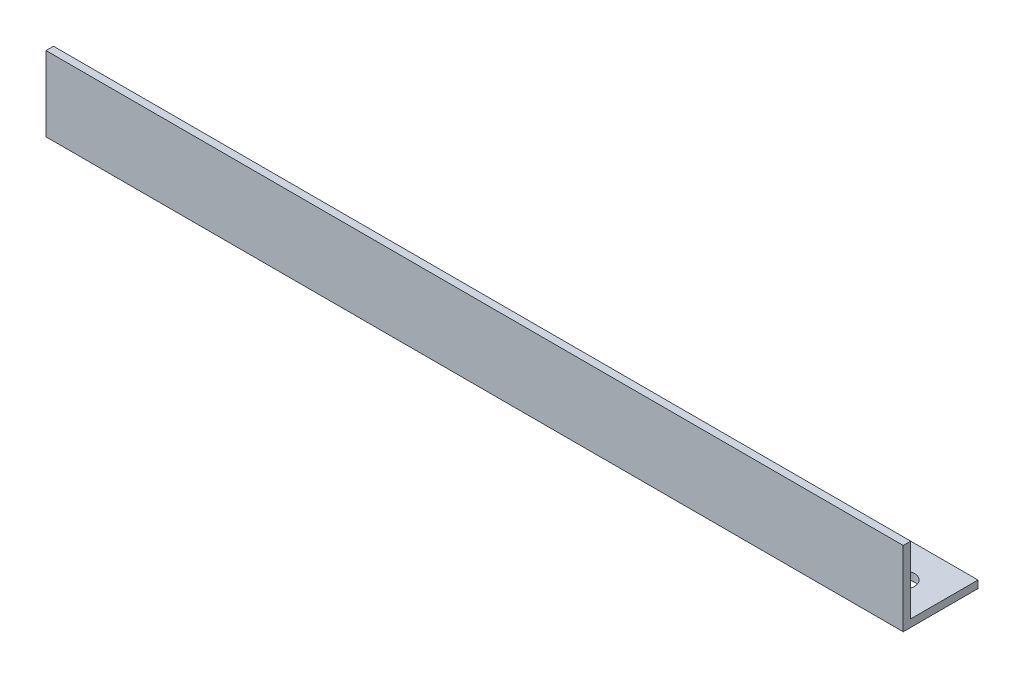
from build123d import *

# Parameters (mm, degrees)
EXTRUDE_1_DEPTH     = 172
SKETCH_2_R          = 2.25
CUT_EXTRUDE_1_DEPTH = 16


with BuildPart() as part:
    # Эскиз1 → Бобышка-Вытянуть1 (new body)
    with BuildSketch(Plane(origin=(0, 0, 0), x_dir=(0, 0, -1), z_dir=(1, 0, 0))):
        Polygon((0, 0), (0, 15), (1.5, 15), (1.5, 1.5), (15, 1.5), (15, 0), align=None)
    extrude(amount=EXTRUDE_1_DEPTH)

    # Эскиз2 → Вырез-Вытянуть1 (cut, through all)
    with BuildSketch(Plane.XZ):
        with Locations((7.5, -7.5)):
            Circle(SKETCH_2_R)
        with Locations((164.5, -7.5)):
            Circle(SKETCH_2_R)
    extrude(amount=-CUT_EXTRUDE_1_DEPTH, mode=Mode.SUBTRACT)


solid = part.part
